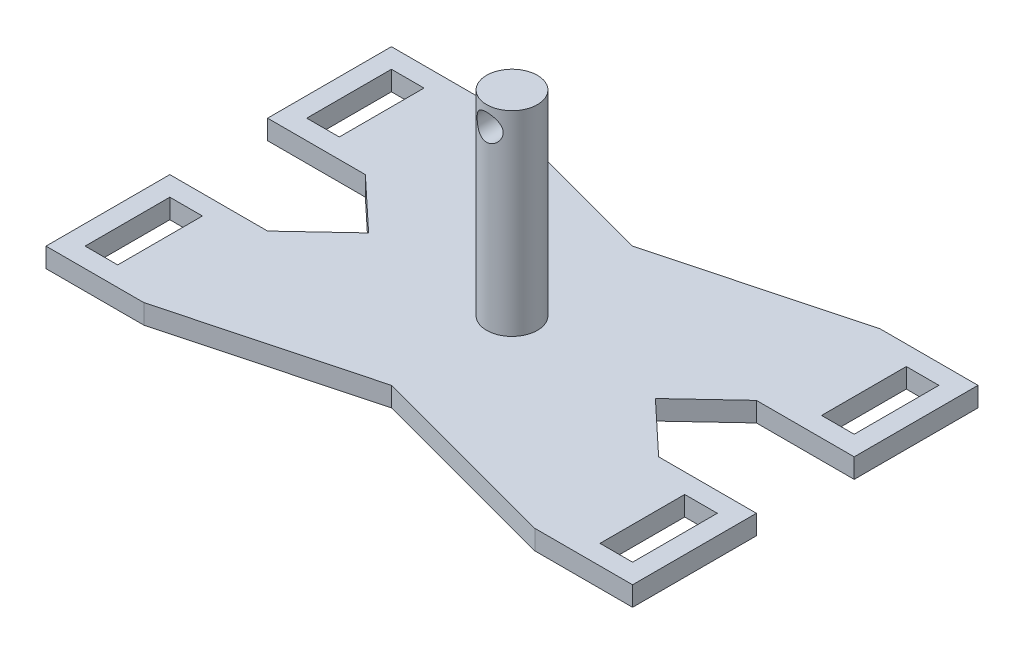
from build123d import *

# Parameters (mm, degrees)
CROQUIS1_W                 = 5
CROQUIS1_H                 = 13
SALIENTE_EXTRUIR1_DEPTH    = 3
CROQUIS9_R                 = 3.9
SALIENTE_EXTRUIR2_DEPTH    = 30
CROQUIS10_R                = 2
CORTAR_EXTRUIR7_DEPTH      = 27.5
CORTAR_EXTRUIR7_DEPTH_BACK = 27.5


with BuildPart() as part:
    # Croquis1 → Saliente-Extruir1 (new body)
    with BuildSketch(Plane(origin=(0, 0, 0), x_dir=(1, 0, 0), z_dir=(0, 1, 0))):
        Polygon((-45, -26.5), (-30, -26.5), (0, -18.5), (30, -26.5), (45, -26.5), (45, -7.5), (30, -7.5), (22, 0), (30, 7.5), (45, 7.5), (45, 26.5), (30, 26.5), (0, 18.5), (-30, 26.5), (-45, 26.5), (-45, 7.5), (-30, 7.5), (-22, 0), (-30, -7.5), (-45, -7.5), align=None)
        with Locations((39.5, -17)):
            Rectangle(CROQUIS1_W, CROQUIS1_H, mode=Mode.SUBTRACT)
        with Locations((39.5, 17)):
            Rectangle(CROQUIS1_W, CROQUIS1_H, mode=Mode.SUBTRACT)
        with Locations((-39.5, 17)):
            Rectangle(CROQUIS1_W, CROQUIS1_H, mode=Mode.SUBTRACT)
        with Locations((-39.5, -17)):
            Rectangle(CROQUIS1_W, CROQUIS1_H, mode=Mode.SUBTRACT)
    extrude(amount=SALIENTE_EXTRUIR1_DEPTH)

    # Croquis9 → Saliente-Extruir2 (add)
    with BuildSketch(Plane(origin=(0, 3, 0), x_dir=(1, 0, 0), z_dir=(0, 1, 0))):
        Circle(CROQUIS9_R)
    extrude(amount=SALIENTE_EXTRUIR2_DEPTH)

    # Croquis10 → Cortar-Extruir7 (cut, two sides)
    with BuildSketch(Plane.XY) as cortar_extruir7_sk:
        with Locations((0, 30)):
            Circle(CROQUIS10_R)
    extrude(amount=CORTAR_EXTRUIR7_DEPTH, mode=Mode.SUBTRACT)
    extrude(cortar_extruir7_sk.sketch, amount=-CORTAR_EXTRUIR7_DEPTH_BACK, mode=Mode.SUBTRACT)


solid = part.part
